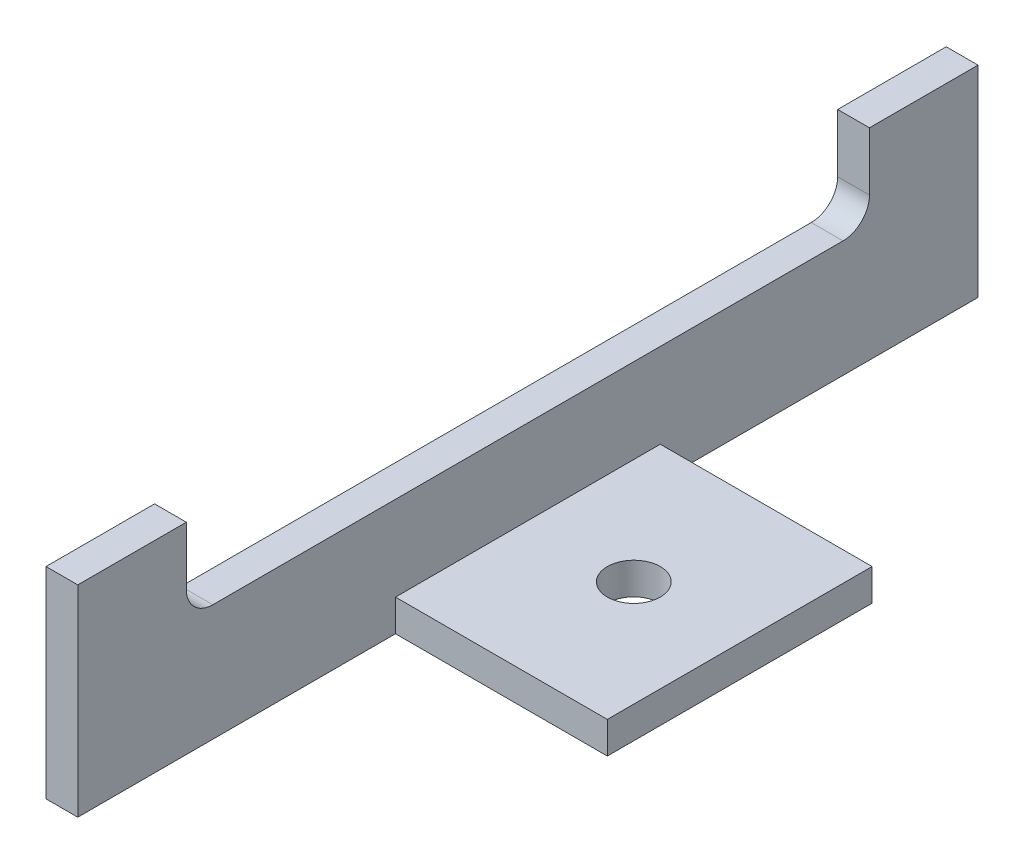
from build123d import *

# Parameters (mm, degrees)
SALIENTE_EXTRUIR1_DEPTH = 170
CROQUIS2_W              = 55
CROQUIS2_H              = 28
CORTAR_EXTRUIR1_DEPTH   = 6
CROQUIS3_W              = 44
CROQUIS3_H              = 60
CORTAR_EXTRUIR2_DEPTH   = 6
CROQUIS4_W              = 4
CROQUIS4_H              = 50
CORTAR_EXTRUIR3_DEPTH   = 10
CROQUIS5_W              = 20.5
CROQUIS5_H              = 12
CROQUIS5_W_2            = 18
CORTAR_EXTRUIR4_DEPTH   = 6
CROQUIS6_W              = 129
CROQUIS6_H              = 16
CORTAR_EXTRUIR5_DEPTH   = 6
CROQUIS7_R              = 5
CORTAR_EXTRUIR6_DEPTH   = 6
REDONDEO1_R             = 5


with BuildPart() as part:
    # Croquis1 → Saliente-Extruir1 (new body)
    with BuildSketch(Plane.XY):
        Polygon((0, 0), (0, 50), (6, 50), (6, 6), (50, 6), (50, 0), align=None)
    extrude(amount=SALIENTE_EXTRUIR1_DEPTH)

    # Croquis2 → Cortar-Extruir1 (cut)
    with BuildSketch(Plane.ZY):
        with Locations((85, 36)):
            Rectangle(CROQUIS2_W, CROQUIS2_H)
        with BuildLine():
            Line((149.5, 35), (149.5, 50))
            Line((149.5, 50), (130.5, 50))
            Line((130.5, 50), (130.5, 35))
            ThreePointArc((130.5, 35), (140, 25.5), (149.5, 35))
        make_face()
        with BuildLine():
            Line((39.5, 35), (39.5, 50))
            Line((39.5, 50), (20.5, 50))
            Line((20.5, 50), (20.5, 35))
            ThreePointArc((20.5, 35), (30, 25.5), (39.5, 35))
        make_face()
    extrude(amount=-CORTAR_EXTRUIR1_DEPTH, mode=Mode.SUBTRACT)

    # Croquis3 → Cortar-Extruir2 (cut)
    with BuildSketch(Plane.XZ):
        with Locations((28, 140)):
            Rectangle(CROQUIS3_W, CROQUIS3_H)
        with Locations((28, 30)):
            Rectangle(CROQUIS3_W, CROQUIS3_H)
    extrude(amount=-CORTAR_EXTRUIR2_DEPTH, mode=Mode.SUBTRACT)

    # Croquis4 → Cortar-Extruir3 (cut)
    with BuildSketch(Plane.XZ):
        with Locations((48, 85)):
            Rectangle(CROQUIS4_W, CROQUIS4_H)
    extrude(amount=-CORTAR_EXTRUIR3_DEPTH, mode=Mode.SUBTRACT)

    # Croquis5 → Cortar-Extruir4 (cut)
    with BuildSketch(Plane.ZY):
        with Locations((159.75, 44)):
            Rectangle(CROQUIS5_W, CROQUIS5_H)
        with Locations((121.5, 44)):
            Rectangle(CROQUIS5_W_2, CROQUIS5_H)
        with Locations((48.5, 44)):
            Rectangle(CROQUIS5_W_2, CROQUIS5_H)
        with Locations((10.25, 44)):
            Rectangle(CROQUIS5_W, CROQUIS5_H)
    extrude(amount=-CORTAR_EXTRUIR4_DEPTH, mode=Mode.SUBTRACT)

    # Croquis6 → Cortar-Extruir5 (cut)
    with BuildSketch(Plane.ZY):
        with Locations((85, 30)):
            Rectangle(CROQUIS6_W, CROQUIS6_H)
    extrude(amount=-CORTAR_EXTRUIR5_DEPTH, mode=Mode.SUBTRACT)

    # Croquis7 → Cortar-Extruir6 (cut)
    with BuildSketch(Plane.XZ):
        with Locations((26, 85)):
            Circle(CROQUIS7_R)
    extrude(amount=-CORTAR_EXTRUIR6_DEPTH, mode=Mode.SUBTRACT)

    # Redondeo1
    redondeo1_edges = [part.edges().sort_by_distance(p)[0] for p in [
        (3, 22, 149.5),
        (3, 22, 20.5),
    ]]
    fillet(redondeo1_edges, radius=REDONDEO1_R)


solid = part.part
